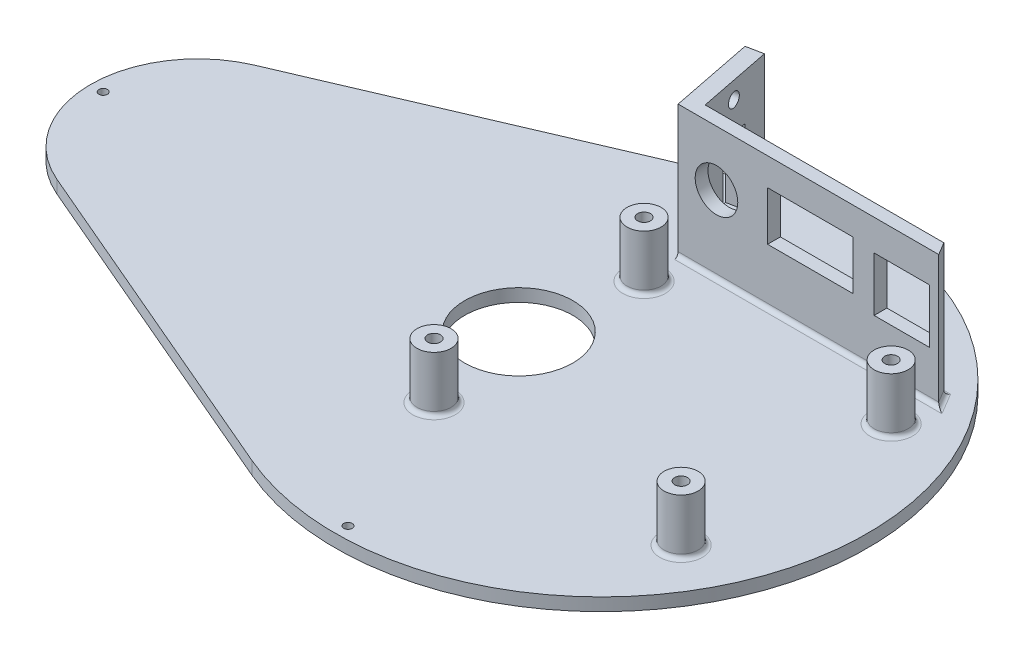
from build123d import *

# Parameters (mm, degrees)
BOSS_EXTRUDE1_DEPTH     = 3
SKETCH2_R               = 4
SKETCH2_R_2             = 1.5
BOSS_EXTRUDE2_DEPTH     = 16
BOSS_EXTRUDE4_DEPTH     = 34
SKETCH6_R               = 5
SKETCH6_W               = 13
SKETCH6_H               = 12.705942109
SKETCH6_W_2             = 20
SKETCH6_H_2             = 11.5
CUT_EXTRUDE1_DEPTH      = 10
CUT_EXTRUDE1_DEPTH_BACK = 5
SKETCH9_R               = 12.7
CUT_EXTRUDE3_DEPTH      = 8
SKETCH10_R              = 1
CUT_EXTRUDE4_DEPTH      = 10
FILLET1_R               = 1
SKETCH11_R              = 1.62
SKETCH11_W              = 6.5
SKETCH11_H              = 17.5
CUT_EXTRUDE5_DEPTH      = 10


with BuildPart() as part:
    # Sketch1 → Boss-Extrude1 (new body)
    with BuildSketch(Plane(origin=(0, 0, 0), x_dir=(1, 0, 0), z_dir=(0, 1, 0))):
        with BuildLine():
            Line((-104.6543947, -23.181164953), (-24.598685103, -57.455675883))
            ThreePointArc((-24.598685103, -57.455675883), (62.5, 0), (-24.598685103, 57.455675883))
            Line((-24.598685103, 57.455675883), (-104.6543947, 23.181164953))
            ThreePointArc((-104.6543947, 23.181164953), (-119.94612383, 0), (-104.6543947, -23.181164953))
        make_face()
    extrude(amount=BOSS_EXTRUDE1_DEPTH)

    # Sketch2 → Boss-Extrude2 (add)
    with BuildSketch(Plane(origin=(0, 0, 0), x_dir=(1, 0, 0), z_dir=(0, 1, 0))):
        with Locations((-14.993702206, -24.304194143)):
            Circle(SKETCH2_R)
        with Locations((-14.993702206, -24.304194143)):
            Circle(SKETCH2_R_2, mode=Mode.SUBTRACT)
        with Locations((43.006297794, -24.304194143)):
            Circle(SKETCH2_R)
        with Locations((43.006297794, -24.304194143)):
            Circle(SKETCH2_R_2, mode=Mode.SUBTRACT)
        with Locations((-14.993702206, 24.995805857)):
            Circle(SKETCH2_R)
        with Locations((-14.993702206, 24.995805857)):
            Circle(SKETCH2_R_2, mode=Mode.SUBTRACT)
        with Locations((43.006297794, 24.995805857)):
            Circle(SKETCH2_R)
        with Locations((43.006297794, 24.995805857)):
            Circle(SKETCH2_R_2, mode=Mode.SUBTRACT)
    extrude(amount=BOSS_EXTRUDE2_DEPTH)

    # Sketch3 → Boss-Extrude4 (add)
    with BuildSketch(Plane(origin=(0, 0, 0), x_dir=(1, 0, 0), z_dir=(0, 1, 0))):
        Polygon((-15.993308679, 33.995805857), (-19.886104129, 53.592683168), (-16.090572218, 54.346641522), (-12.643938704, 36.995805857), (43.389376911, 36.995805857), (45.167410352, 33.995805857), align=None)
    extrude(amount=BOSS_EXTRUDE4_DEPTH)

    # Sketch6 → Cut-Extrude1 (cut, two sides)
    with BuildSketch(Plane(origin=(0, 0, -35.995805857), x_dir=(-1, 0, 0), z_dir=(0, 0, -1))) as cut_extrude1_sk:
        with Locations((6.993702206, 21)):
            Circle(SKETCH6_R)
        with Locations((-36.506297794, 20.388898665)):
            Rectangle(SKETCH6_W, SKETCH6_H)
        with Locations((-15.006297794, 21.75)):
            Rectangle(SKETCH6_W_2, SKETCH6_H_2)
    extrude(amount=CUT_EXTRUDE1_DEPTH, mode=Mode.SUBTRACT)
    extrude(cut_extrude1_sk.sketch, amount=-CUT_EXTRUDE1_DEPTH_BACK, mode=Mode.SUBTRACT)

    # Sketch9 → Cut-Extrude3 (cut)
    with BuildSketch(Plane(origin=(0, 3, 0), x_dir=(1, 0, 0), z_dir=(0, 1, 0))):
        with Locations((-19.402851724, 0)):
            Circle(SKETCH9_R)
    extrude(amount=-CUT_EXTRUDE3_DEPTH, mode=Mode.SUBTRACT)

    # Sketch10 → Cut-Extrude4 (cut)
    with BuildSketch(Plane(origin=(0, 3, 0), x_dir=(1, 0, 0), z_dir=(0, 1, 0))):
        with Locations((-116.94612383, 0)):
            Circle(SKETCH10_R)
        with Locations((0, -59.5)):
            Circle(SKETCH10_R)
        with Locations((0, 59.489452719)):
            Circle(SKETCH10_R)
    extrude(amount=-CUT_EXTRUDE4_DEPTH, mode=Mode.SUBTRACT)

    # Fillet1
    fillet1_edges = [part.edges().sort_by_distance(p)[0] for p in [
        (-18.993702206, 3, 24.304194143),
        (39.006297794, 3, 24.304194143),
        (-18.993702206, 3, -24.995805857),
        (39.006297794, 3, -24.995805857),
        (14.587050836, 3, -33.995805857),
        (44.278393631, 3, -35.495805857),
        (15.372719104, 3, -36.995805857),
    ]]
    fillet(fillet1_edges, radius=FILLET1_R)

    # Sketch11 → Cut-Extrude5 (cut)
    with BuildSketch(Plane(origin=(-5.09395257, 0, 1.011881387), x_dir=(-0.19483679, 0, -0.980835677), z_dir=(0.980835677, 0, -0.19483679))):
        with Locations((47.325532424, 29.998886712)):
            Circle(SKETCH11_R)
        with Locations((47.325532424, 14.458886712)):
            Rectangle(SKETCH11_W, SKETCH11_H)
    extrude(amount=-CUT_EXTRUDE5_DEPTH, mode=Mode.SUBTRACT)


solid = part.part
